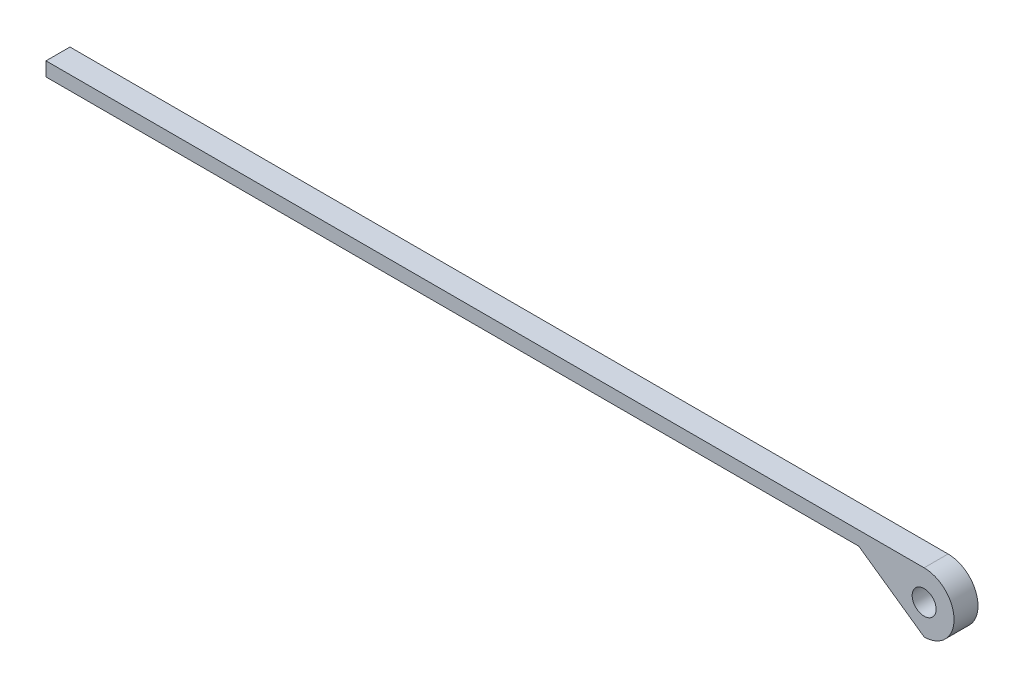
from build123d import *

# Parameters (mm, degrees)
SKETCH1_R           = 3
BOSS_EXTRUDE1_DEPTH = 6


with BuildPart() as part:
    # Sketch1 → Boss-Extrude1 (new body)
    with BuildSketch(Plane.XY):
        with BuildLine():
            Line((210, 399.806072497), (-10, 399.806072497))
            Line((-10, 399.806072497), (-10, 396.306072497))
            Line((-10, 396.306072497), (193.636931828, 396.306072497))
            Line((193.636931828, 396.306072497), (210, 384.806072497))
            ThreePointArc((210, 384.806072497), (217.5, 392.306072497), (210, 399.806072497))
        make_face()
        with Locations((210, 392.306072497)):
            Circle(SKETCH1_R, mode=Mode.SUBTRACT)
    extrude(amount=BOSS_EXTRUDE1_DEPTH)


solid = part.part
